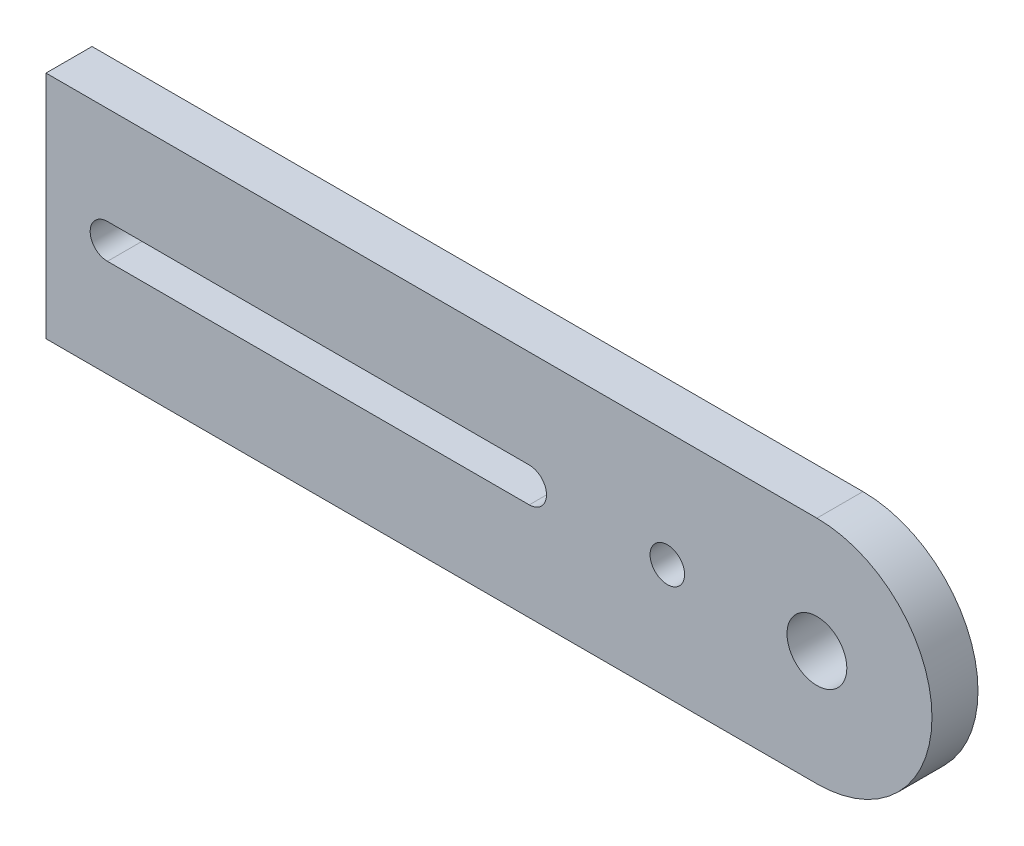
from build123d import *

# Parameters (mm, degrees)
BOSS_EXTRUDE1_DEPTH = 4
SKETCH2_R           = 2.6
CUT_EXTRUDE1_DEPTH  = 4
SKETCH3_R           = 1.5
CUT_EXTRUDE2_DEPTH  = 4
FILLET1_R           = 3
SKETCH4_W           = 40
SKETCH4_H           = 20
BOSS_EXTRUDE2_DEPTH = 4
SKETCH5_R           = 1.5
CUT_EXTRUDE3_DEPTH  = 4
SKETCH6_W           = 36.661625307
SKETCH6_H           = 3
CUT_EXTRUDE4_DEPTH  = 4


with BuildPart() as part:
    # Sketch1 → Boss-Extrude1 (new body)
    with BuildSketch(Plane.XY):
        with BuildLine():
            Line((-15, 10), (-15, -10))
            Line((-15, -10), (15, -10))
            ThreePointArc((15, -10), (5, 0), (15, 10))
            Line((15, 10), (-15, 10))
        make_face()
        with BuildLine():
            ThreePointArc((15, 10), (5, 0), (15, -10))
            Line((15, -10), (15, 10))
        make_face()
        with BuildLine():
            Line((15, 10), (15, -10))
            ThreePointArc((15, -10), (22.071067812, -7.071067812), (25, 0))
            ThreePointArc((25, 0), (22.071067812, 7.071067812), (15, 10))
        make_face()
    extrude(amount=BOSS_EXTRUDE1_DEPTH)

    # Sketch2 → Cut-Extrude1 (cut)
    with BuildSketch(Plane.XY.offset(4)):
        with Locations((15, 0)):
            Circle(SKETCH2_R)
    extrude(amount=-CUT_EXTRUDE1_DEPTH, mode=Mode.SUBTRACT)

    # Sketch3 → Cut-Extrude2 (cut)
    with BuildSketch(Plane.XY.offset(4)):
        with Locations((-10, 0)):
            Circle(SKETCH3_R)
        with Locations((2, 0)):
            Circle(SKETCH3_R)
    extrude(amount=-CUT_EXTRUDE2_DEPTH, mode=Mode.SUBTRACT)

    # Fillet1
    fillet1_edges = [part.edges().sort_by_distance(p)[0] for p in [
        (-15, -10, 2),
        (-15, 10, 2),
    ]]
    fillet(fillet1_edges, radius=FILLET1_R)

    # Sketch4 → Boss-Extrude2 (add)
    with BuildSketch(Plane.XY.offset(4)):
        with Locations((-32, 0)):
            Rectangle(SKETCH4_W, SKETCH4_H)
    extrude(amount=-BOSS_EXTRUDE2_DEPTH)

    # Sketch5 → Cut-Extrude3 (cut)
    with BuildSketch(Plane.XY.offset(4)):
        with Locations((-46.661625307, 0)):
            Circle(SKETCH5_R)
    extrude(amount=-CUT_EXTRUDE3_DEPTH, mode=Mode.SUBTRACT)

    # Sketch6 → Cut-Extrude4 (cut)
    with BuildSketch(Plane.XY.offset(4)):
        with Locations((-28.330812654, 0)):
            Rectangle(SKETCH6_W, SKETCH6_H)
    extrude(amount=-CUT_EXTRUDE4_DEPTH, mode=Mode.SUBTRACT)


solid = part.part
